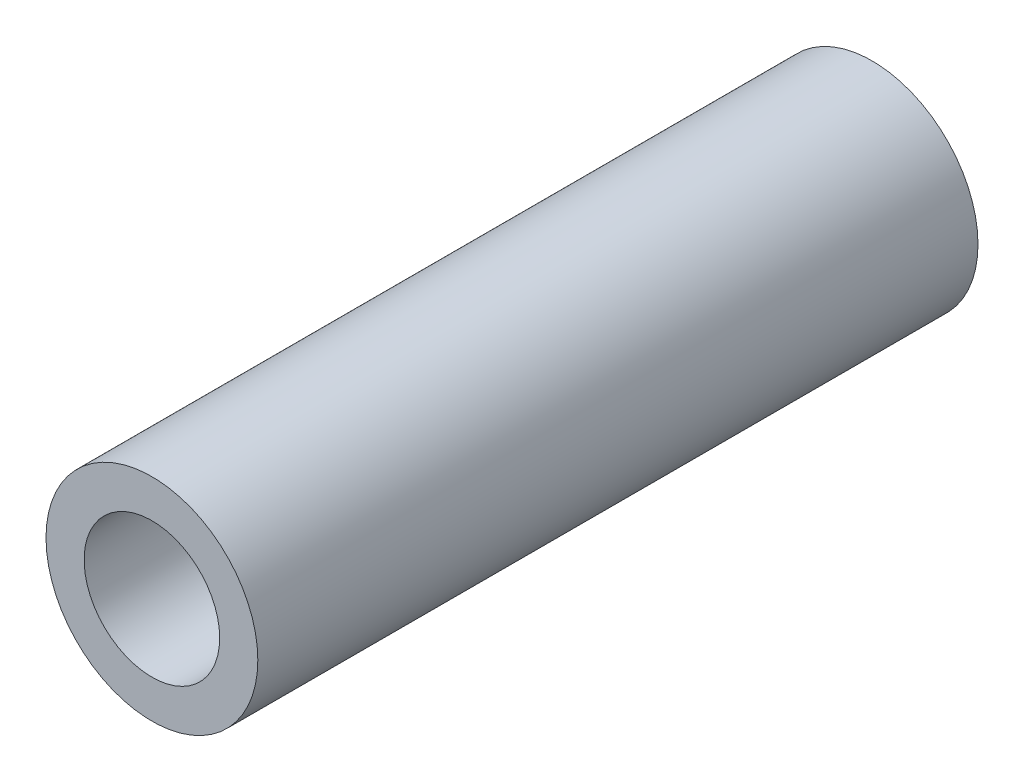
from build123d import *

# Parameters (mm, degrees)
SKETCH1_R           = 2.5
SKETCH1_R_2         = 1.6
BOSS_EXTRUDE1_DEPTH = 17


with BuildPart() as part:
    # Sketch1 → Boss-Extrude1 (new body)
    with BuildSketch(Plane.XY):
        Circle(SKETCH1_R)
        Circle(SKETCH1_R_2, mode=Mode.SUBTRACT)
    extrude(amount=BOSS_EXTRUDE1_DEPTH)


solid = part.part
